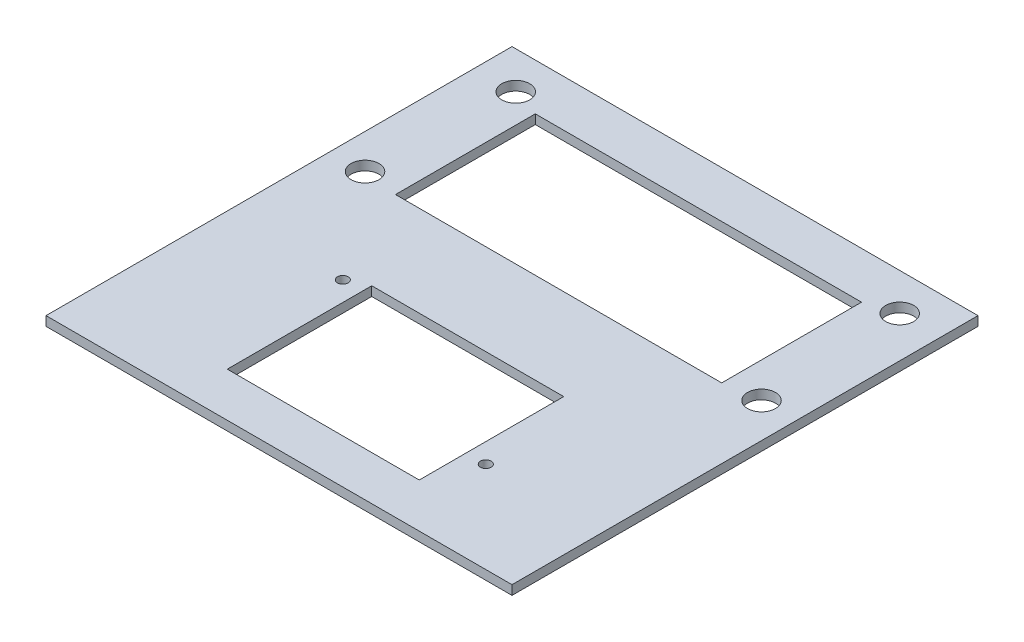
from build123d import *

# Parameters (mm, degrees)
SKETCH1_W           = 63.5
SKETCH1_H           = 63.5
BOSS_EXTRUDE1_DEPTH = 1.27
SKETCH2_R           = 1.905
CUT_EXTRUDE1_DEPTH  = 1.27
SKETCH3_W           = 44.45
SKETCH3_H           = 19.05
CUT_EXTRUDE2_DEPTH  = 1.27
SKETCH4_R           = 0.73025
BOSS_EXTRUDE2_DEPTH = 3.81
CUT_EXTRUDE3_REACH  = 5.81
SKETCH5_W           = 26.162
SKETCH5_H           = 19.685
SKETCH6_R           = 0.73025
CUT_EXTRUDE4_DEPTH  = 4.81


with BuildPart() as part:
    # Sketch1 → Boss-Extrude1 (new body)
    with BuildSketch(Plane(origin=(0, 0, 0), x_dir=(1, 0, 0), z_dir=(0, 1, 0))):
        Rectangle(SKETCH1_W, SKETCH1_H)
    extrude(amount=BOSS_EXTRUDE1_DEPTH)

    # Sketch2 → Cut-Extrude1 (cut)
    with BuildSketch(Plane(origin=(0, 1.27, 0), x_dir=(1, 0, 0), z_dir=(0, 1, 0))):
        with Locations((27.0129, 6.985)):
            Circle(SKETCH2_R)
        with Locations((26.162, 26.67)):
            Circle(SKETCH2_R)
        with Locations((-27.0129, 6.985)):
            Circle(SKETCH2_R)
        with Locations((-26.162, 26.67)):
            Circle(SKETCH2_R)
    extrude(amount=-CUT_EXTRUDE1_DEPTH, mode=Mode.SUBTRACT)

    # Sketch3 → Cut-Extrude2 (cut)
    with BuildSketch(Plane(origin=(0, 1.27, 0), x_dir=(1, 0, 0), z_dir=(0, 1, 0))):
        with Locations((0, 15.875)):
            Rectangle(SKETCH3_W, SKETCH3_H)
    extrude(amount=-CUT_EXTRUDE2_DEPTH, mode=Mode.SUBTRACT)

    # Sketch4 → Boss-Extrude2 (add)
    with BuildSketch(Plane(origin=(0, 1.27, 0), x_dir=(1, 0, 0), z_dir=(0, 1, 0))):
        with Locations((-15.748, -7.3025)):
            Circle(SKETCH4_R)
        with Locations((15.748, -19.3167)):
            Circle(SKETCH4_R)
    extrude(amount=-BOSS_EXTRUDE2_DEPTH)

    # Sketch5 → Cut-Extrude3 (cut, up to next)
    with BuildSketch(Plane(origin=(0, 1.27, 0), x_dir=(1, 0, 0), z_dir=(0, 1, 0)), mode=Mode.PRIVATE) as cut_extrude3_sk1:
        with Locations((0, -15.875)):
            Rectangle(SKETCH5_W, SKETCH5_H)
    cut_extrude3_tool1 = extrude(cut_extrude3_sk1.sketch, amount=-CUT_EXTRUDE3_REACH, mode=Mode.PRIVATE) & part.part
    add(cut_extrude3_tool1.solids().sort_by_distance((0, 1.27, 15.875))[0], mode=Mode.SUBTRACT)

    # Sketch6 → Cut-Extrude4 (cut, through all)
    with BuildSketch(Plane.XZ.offset(2.54)):
        with Locations((15.748, 19.3167)):
            Circle(SKETCH6_R)
        with Locations((-15.748, 7.3025)):
            Circle(SKETCH6_R)
    extrude(amount=-CUT_EXTRUDE4_DEPTH, mode=Mode.SUBTRACT)


solid = part.part
